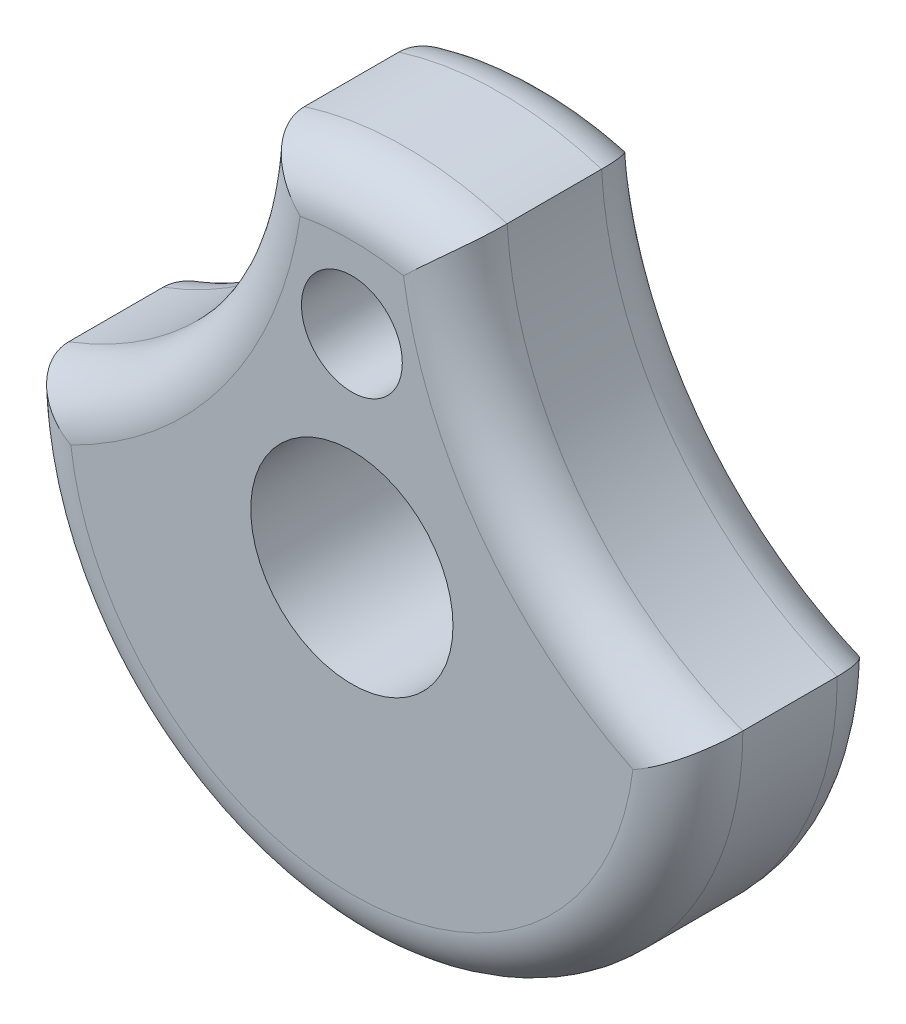
from build123d import *

# Parameters (mm, degrees)
SKETCH1_R           = 15.875
SKETCH1_R_2         = 4.7625
SKETCH1_R_3         = 2.3749
BOSS_EXTRUDE1_DEPTH = 9.525
CUT_EXTRUDE1_DEPTH  = 10.525
FILLET1_R           = 2.54
FILLET2_R           = 2.54


with BuildPart() as part:
    # Sketch1 → Boss-Extrude1 (new body)
    with BuildSketch(Plane.XY):
        Circle(SKETCH1_R)
        Circle(SKETCH1_R_2, mode=Mode.SUBTRACT)
        with Locations((0, 9.525)):
            Circle(SKETCH1_R_3, mode=Mode.SUBTRACT)
    extrude(amount=-BOSS_EXTRUDE1_DEPTH)

    # Sketch2 → Cut-Extrude1 (cut, through all)
    with BuildSketch(Plane.XY):
        with BuildLine():
            ThreePointArc((-15.875, 0), (-8.06886604, 5.915724645), (-4.7752, 15.139785004))
            ThreePointArc((-4.7752, 15.139785004), (-12.802771673, 9.386408392), (-15.875, 0))
        make_face()
        with BuildLine():
            ThreePointArc((15.875, 0), (8.06886604, 5.915724645), (4.7752, 15.139785004))
            ThreePointArc((4.7752, 15.139785004), (12.802771673, 9.386408392), (15.875, 0))
        make_face()
    extrude(amount=-CUT_EXTRUDE1_DEPTH, mode=Mode.SUBTRACT)

    # Fillet1
    fillet1_edges = [part.edges().sort_by_distance(p)[0] for p in [
        (0, 15.875, 0),
        (0, -15.875, 0),
        (-8.06886604, 5.915724645, 0),
        (8.06886604, 5.915724645, 0),
    ]]
    fillet(fillet1_edges, radius=FILLET1_R)

    # Fillet2
    fillet2_edges = [part.edges().sort_by_distance(p)[0] for p in [
        (0, 15.875, -9.525),
        (0, -15.875, -9.525),
        (-8.06886604, 5.915724645, -9.525),
        (8.06886604, 5.915724645, -9.525),
    ]]
    fillet(fillet2_edges, radius=FILLET2_R)


solid = part.part
